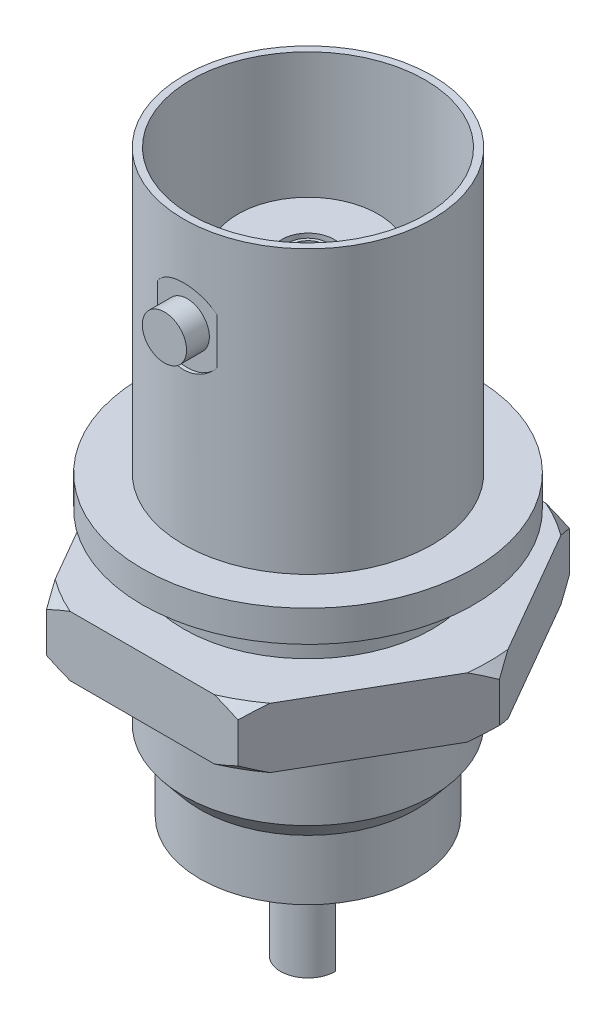
from build123d import *

# Parameters (mm, degrees)
BOSS_EXTRUDE1_START = 1.6
SKETCH2_R           = 4.7625
BOSS_EXTRUDE1_DEPTH = 2.3
BOSS_EXTRUDE2_START = 4.5
SKETCH5_R           = 0.846945363
BOSS_EXTRUDE2_DEPTH = 1
SKETCH6_R           = 0.645187132
CUT_EXTRUDE1_DEPTH  = 5
SKETCH9_W           = 0.137399245
SKETCH9_H           = 0.594121804
BOSS_EXTRUDE3_DEPTH = 3
SKETCH11_R          = 0.94402027
CUT_EXTRUDE2_DEPTH  = 3
SKETCH13_R          = 0.99938664
SKETCH13_R_2        = 0.759397748
CUT_EXTRUDE4_DEPTH  = 4


with BuildPart() as part:
    # Sketch1 → Revolve1 (revolve)
    with BuildSketch(Plane.XY):
        Polygon((0, 7.249356935), (-2.68096621, 7.249356935), (-2.68096621, 0), (-4.484856827, 0), (-4.484856827, 10.8), (-4.7625, 10.8), (-4.7625, 0), (-6.35, 0), (-6.35, -1.2), (-4.7625, -1.2), (-4.7625, -8.33684753), (-4.138651138, -9.1), (-4.138651138, -11.4), (-1.05, -11.4), (-1.05, -13.015612484), (0, -13.015612484), align=None)
    revolve(axis=Axis((0, 72.402332312, 0), (0, -1, 0)))

    # Sketch2 → Boss-Extrude1 (add)
    with BuildSketch(Plane.XZ.offset(1.2).offset(BOSS_EXTRUDE1_START)):
        Polygon((3.666174209, -6.35), (7.332348419, 0), (3.666174209, 6.35), (-3.666174209, 6.35), (-7.332348419, 0), (-3.666174209, -6.35), align=None)
        Circle(SKETCH2_R, mode=Mode.SUBTRACT)
    extrude(amount=BOSS_EXTRUDE1_DEPTH)

    # Sketch4 → Cut-Revolve1 (revolve, cut)
    with BuildSketch(Plane.XY):
        Polygon((-6.925646916, -2.8), (-7.332348419, -3.186501065), (-8.999279983, -3.186501065), (-8.361056601, -0.327260314), (-6.925646916, 0.349979738), align=None)
        Polygon((-6.925646916, -8.249979738), (-6.925646916, -5.1), (-7.332348419, -4.713498935), (-8.999279983, -4.713498935), (-8.361056601, -7.572739686), align=None)
    revolve(axis=Axis((0, 10.8, 0), (0, -1, 0)), mode=Mode.SUBTRACT)

    # Sketch5 → Boss-Extrude2 (add)
    with BuildSketch(Plane.XY.offset(BOSS_EXTRUDE2_START)):
        with Locations((0, 7.245112304)):
            Circle(SKETCH5_R)
    boss_extrude2 = extrude(amount=BOSS_EXTRUDE2_DEPTH)

    # Mirror1: Boss-Extrude2 across plane
    add(boss_extrude2.mirror(Plane.XY))

    # Sketch6 → Cut-Extrude1 (cut)
    with BuildSketch(Plane(origin=(0, 7.249356935, 0), x_dir=(1, 0, 0), z_dir=(0, 1, 0))):
        Circle(SKETCH6_R)
    extrude(amount=-CUT_EXTRUDE1_DEPTH, mode=Mode.SUBTRACT)

    # Sketch9 → Cut-Revolve2 (revolve, cut)
    with BuildSketch(Plane(origin=(0, 0, 0), x_dir=(0, 0, -1), z_dir=(1, 0, 0))):
        with Locations((4.693800378, 8.389118569)):
            Rectangle(SKETCH9_W, SKETCH9_H)
        with Locations((-4.693800378, 8.389118569)):
            Rectangle(SKETCH9_W, SKETCH9_H)
    revolve(axis=Axis((0, 7.245112304, 5.5), (0, 0, -1)), mode=Mode.SUBTRACT)

    # Sketch10 → Boss-Extrude3 (add)
    with BuildSketch(Plane.XZ.offset(13.015612484)):
        with BuildLine():
            Line((0.94402027, 0), (1.05, 0))
            ThreePointArc((1.05, 0), (0, 1.05), (-1.05, 0))
            Line((-1.05, 0), (-0.94402027, 0))
            ThreePointArc((-0.94402027, 0), (0, 0.94402027), (0.94402027, 0))
        make_face()
    extrude(amount=BOSS_EXTRUDE3_DEPTH)

    # Sketch11 → Cut-Extrude2 (cut)
    with BuildSketch(Plane.XZ.offset(13.015612484)):
        Circle(SKETCH11_R)
    extrude(amount=-CUT_EXTRUDE2_DEPTH, mode=Mode.SUBTRACT)

    # Sketch13 → Cut-Extrude4 (cut)
    with BuildSketch(Plane(origin=(0, 7.249356935, 0), x_dir=(1, 0, 0), z_dir=(0, 1, 0))):
        Circle(SKETCH13_R)
        Circle(SKETCH13_R_2, mode=Mode.SUBTRACT)
    extrude(amount=-CUT_EXTRUDE4_DEPTH, mode=Mode.SUBTRACT)


solid = part.part
